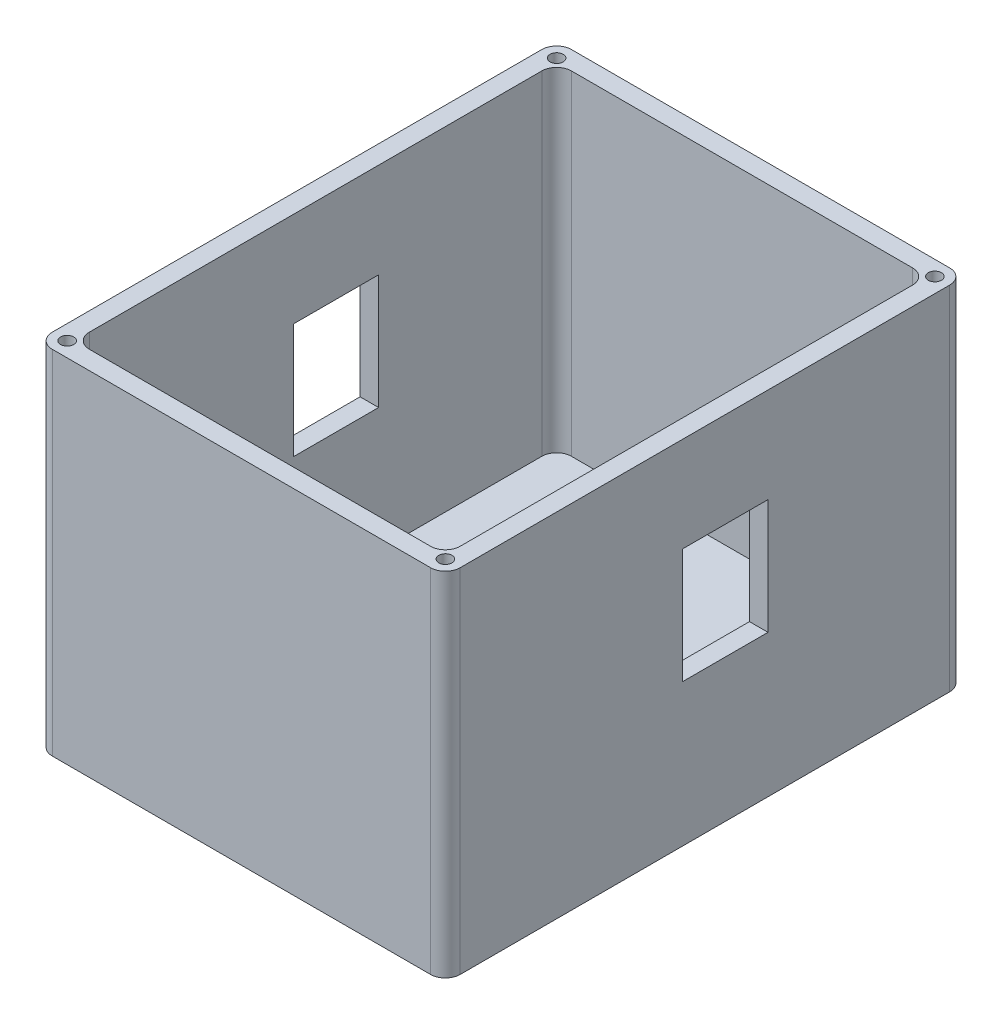
from build123d import *

# Parameters (mm, degrees)
SKETCH1_W                 = 63.5
SKETCH1_H                 = 82.55
BOSS_EXTRUDE1_DEPTH       = 57.15
SHELL1_T                  = 3.175
SKETCH3_R                 = 3.175
BOSS_EXTRUDE2_DEPTH       = 3.175
SKETCH2_R                 = 0.9525
CUT_EXTRUDE1_DEPTH        = 6.35
CUT_EXTRUDE1_DEPTH_BACK   = 0.0127
FILLET1_R                 = 2.54
SKETCH4_W                 = 12.192
SKETCH4_H                 = 10.922
CUT_EXTRUDE2_DEPTH        = 123.721040372
SKETCH5_W                 = 14.605
SKETCH5_H                 = 19.685
CUT_EXTRUDE3_DEPTH        = 125.474578228
F_4_40_TAPPED_HOLE1_D     = 2.2606
F_4_40_TAPPED_HOLE1_DEPTH = 6.35
F_4_40_TAPPED_HOLE1_TIP   = 0.679152758


with BuildPart() as part:
    # Sketch1 → Boss-Extrude1 (new body)
    with BuildSketch(Plane(origin=(0, 0, 0), x_dir=(1, 0, 0), z_dir=(0, 1, 0))):
        with Locations((31.75, -41.275)):
            Rectangle(SKETCH1_W, SKETCH1_H)
    extrude(amount=BOSS_EXTRUDE1_DEPTH)

    # Shell1
    shell1_openings = [part.faces().sort_by_distance(p)[0] for p in [
        (31.75, 57.15, 41.275),
    ]]
    offset(amount=SHELL1_T, openings=shell1_openings, kind=Kind.INTERSECTION)

    # Sketch3 → Boss-Extrude2 (add)
    with BuildSketch(Plane(origin=(0, 0, 0), x_dir=(1, 0, 0), z_dir=(0, 1, 0))):
        with Locations(Location((12.827, -68.58, 0), (0, 0, 270))):
            Circle(SKETCH3_R)
        with Locations(Location((40.132, -68.58, 0), (0, 0, 270))):
            Circle(SKETCH3_R)
        with Locations(Location((56.007, -17.78, 0), (0, 0, 270))):
            Circle(SKETCH3_R)
    extrude(amount=BOSS_EXTRUDE2_DEPTH)

    # Sketch2 → Cut-Extrude1 (cut, two sides)
    with BuildSketch(Plane(origin=(0, 0, 0), x_dir=(1, 0, 0), z_dir=(0, 1, 0))) as cut_extrude1_sk:
        with Locations(Location((12.827, -68.58, 0), (0, 0, 270))):
            Circle(SKETCH2_R)
        with Locations(Location((40.132, -68.58, 0), (0, 0, 270))):
            Circle(SKETCH2_R)
        with Locations(Location((56.007, -17.78, 0), (0, 0, 270))):
            Circle(SKETCH2_R)
    extrude(amount=CUT_EXTRUDE1_DEPTH, mode=Mode.SUBTRACT)
    extrude(cut_extrude1_sk.sketch, amount=-CUT_EXTRUDE1_DEPTH_BACK, mode=Mode.SUBTRACT)

    # Fillet1
    fillet1_edges = [part.edges().sort_by_distance(p)[0] for p in [
        (0, 28.575, 0),
        (0, 28.575, 82.55),
        (63.5, 28.575, 82.55),
        (63.5, 28.575, 0),
        (-3.175, 26.9875, -3.175),
        (66.675, 26.9875, -3.175),
        (66.675, 26.9875, 85.725),
        (-3.175, 26.9875, 85.725),
    ]]
    fillet(fillet1_edges, radius=FILLET1_R)

    # Sketch4 → Cut-Extrude2 (cut, through all)
    with BuildSketch(Plane.XY):
        with Locations((42.799, 10.287)):
            Rectangle(SKETCH4_W, SKETCH4_H)
    extrude(amount=-CUT_EXTRUDE2_DEPTH, mode=Mode.SUBTRACT)

    # Sketch5 → Cut-Extrude3 (cut, through all)
    with BuildSketch(Plane(origin=(66.675, 0, 0), x_dir=(0, 0, -1), z_dir=(1, 0, 0))):
        with Locations((-37.7825, 31.0515)):
            Rectangle(SKETCH5_W, SKETCH5_H)
    extrude(amount=-CUT_EXTRUDE3_DEPTH, mode=Mode.SUBTRACT)

    # #4-40 Tapped Hole1
    with Locations(Plane(origin=(0, 57.15, 0), x_dir=(1, 0, 0), z_dir=(0, 1, 0))):
        with Locations((64.135, -83.185), (-0.635, -83.185), (-0.635, 0.635), (64.135, 0.635)):
            Hole(F_4_40_TAPPED_HOLE1_D / 2, depth=F_4_40_TAPPED_HOLE1_DEPTH)
            with Locations((0, 0, -(F_4_40_TAPPED_HOLE1_DEPTH + F_4_40_TAPPED_HOLE1_TIP / 2))):  # 118° drill point
                Cone(0, F_4_40_TAPPED_HOLE1_D / 2, F_4_40_TAPPED_HOLE1_TIP, mode=Mode.SUBTRACT)


solid = part.part
